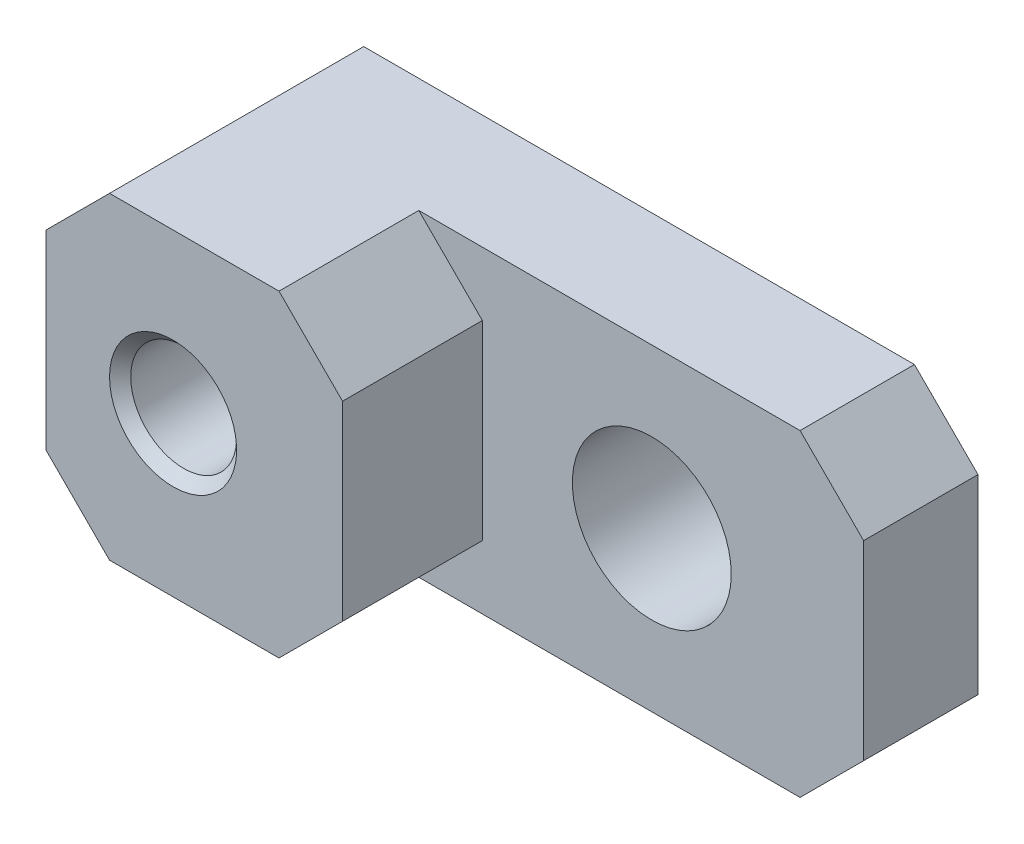
from build123d import *

# Parameters (mm, degrees)
SKETCH1_W                      = 20.32
SKETCH1_H                      = 9.525
EXTRUDE1_DEPTH                 = 7.62
F_3_16_0_1875_DIAMETER_HOLE1_D = 4.7625
SKETCH4_W                      = 11.43
SKETCH4_H                      = 9.525
EXTRUDE2_DEPTH                 = 4.191
CHAMFER1_SIZE                  = 1.905


with BuildPart() as part:
    # Sketch1 → Extrude1 (new body)
    with BuildSketch(Plane.XY):
        with Locations((10.16, 4.7625)):
            Rectangle(SKETCH1_W, SKETCH1_H)
    extrude(amount=EXTRUDE1_DEPTH)

    # 3/16 (0.1875) Diameter Hole1 (through all)
    with Locations(Plane(origin=(4.042308369, -0.495150795, 7.62), x_dir=(-1, 0, 0), z_dir=(0, 0, 1))):
        with Locations((-9.927691631, -5.257650795)):
            Hole(F_3_16_0_1875_DIAMETER_HOLE1_D / 2)

    # Sketch4 → Extrude2 (cut)
    with BuildSketch(Plane.XY.offset(7.62)):
        with Locations((14.605, 4.7625)):
            Rectangle(SKETCH4_W, SKETCH4_H)
    extrude(amount=-EXTRUDE2_DEPTH, mode=Mode.SUBTRACT)

    # Chamfer1
    chamfer1_edges = [part.edges().sort_by_distance(p)[0] for p in [
        (20.32, 9.525, 1.7145),
        (20.32, 0, 1.7145),
        (8.89, 9.525, 5.5245),
        (8.89, 0, 5.5245),
        (0, 9.525, 3.81),
        (0, 0, 3.81),
    ]]
    chamfer(chamfer1_edges, length=CHAMFER1_SIZE)

    # Sketch5 → CBORE for #4 Socket Head Cap Screw1 (revolve, cut)
    with BuildSketch(Plane(origin=(3.81, 4.7625, 0), x_dir=(0, 1, 0), z_dir=(1, 0, 0))):
        Polygon((0, 0), (0, 7.62), (1.905, 7.62), (1.5875, 7.3025), (1.5875, 1.524), (1.6002, 1.524), (1.6002, 0.3048), (1.905, 0), align=None)
    revolve(axis=Axis((3.81, 4.7625, -6.35), (0, 0, 1)), mode=Mode.SUBTRACT)


solid = part.part
